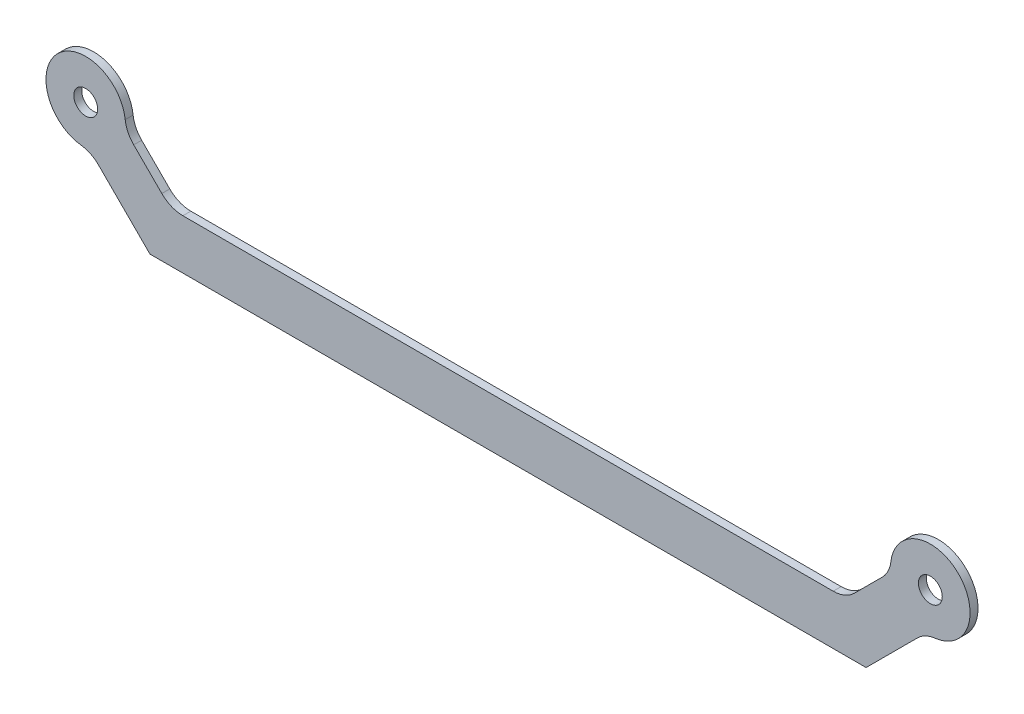
from build123d import *

# Parameters (mm, degrees)
BOSS_EXTRUDE1_DEPTH      = 0.8
SKETCH7_R                = 4
BOSS_EXTRUDE2_DEPTH      = 0.8
FILLET1_R                = 3
M2_CLEARANCE_HOLE1_D     = 2.4
M2_CLEARANCE_HOLE1_DEPTH = 30.5


with BuildPart() as part:
    # Sketch3 → Boss-Extrude1 (new body)
    with BuildSketch(Plane.XY):
        with BuildLine():
            Line((-40.732233047, 1.767766953), (-33.964466094, -5))
            Line((-33.964466094, -5), (33.964466094, -5))
            Line((33.964466094, -5), (40.732233047, 1.767766953))
            ThreePointArc((40.732233047, 1.767766953), (44.267766953, 1.767766953), (44.267766953, -1.767766953))
            Line((44.267766953, -1.767766953), (36.035533906, -10))
            Line((36.035533906, -10), (-36.035533906, -10))
            Line((-36.035533906, -10), (-44.267766953, -1.767766953))
            ThreePointArc((-44.267766953, -1.767766953), (-44.267766953, 1.767766953), (-40.732233047, 1.767766953))
        make_face()
    extrude(amount=BOSS_EXTRUDE1_DEPTH)

    # Sketch7 → Boss-Extrude2 (add)
    with BuildSketch(Plane.XY.offset(0.8)):
        with Locations((-42.5, 0)):
            Circle(SKETCH7_R)
        with Locations((42.5, 0)):
            Circle(SKETCH7_R)
    extrude(amount=-BOSS_EXTRUDE2_DEPTH)

    # Fillet1
    fillet1_edges = [part.edges().sort_by_distance(p)[0] for p in [
        (-33.964466094, -5, 0.4),
        (33.964466094, -5, 0.4),
        (-42.059826736, -3.97570717, 0.4),
        (-38.52429283, -0.440173264, 0.4),
        (42.059826736, -3.97570717, 0.4),
        (38.52429283, -0.440173264, 0.4),
    ]]
    fillet(fillet1_edges, radius=FILLET1_R)

    # M2 Clearance Hole1
    with Locations(Plane.XY.offset(0.8)):
        with Locations((-42.5, 0), (42.5, 0)):
            Hole(M2_CLEARANCE_HOLE1_D / 2, depth=M2_CLEARANCE_HOLE1_DEPTH)


solid = part.part
